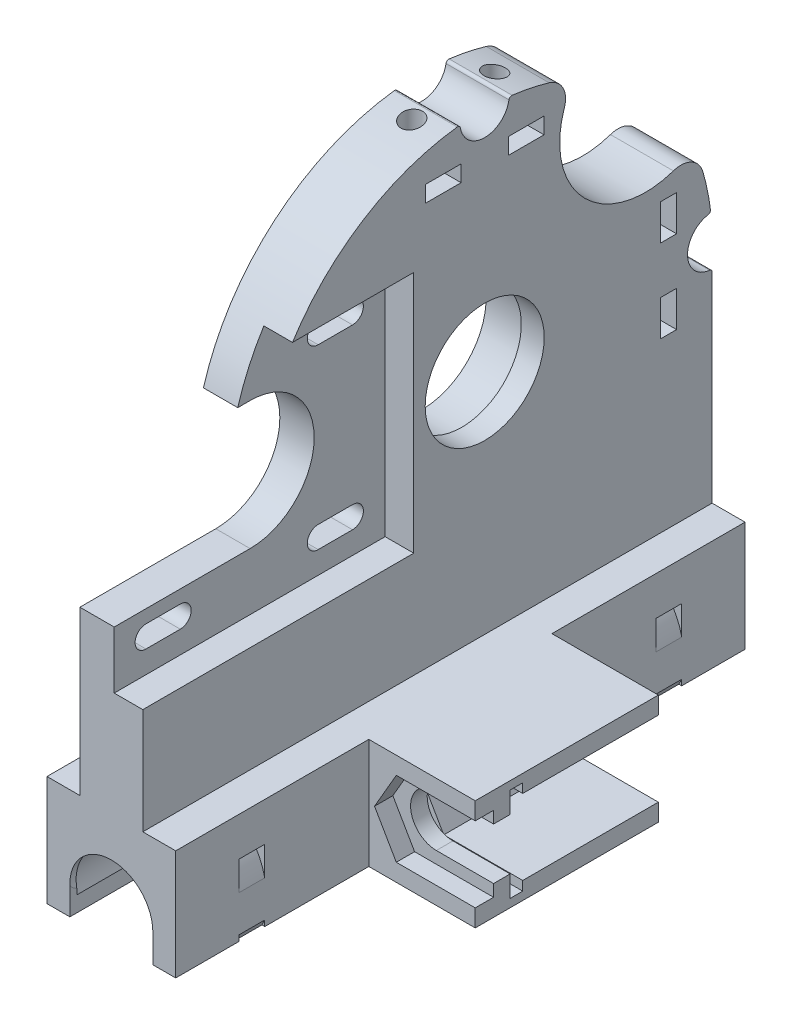
from build123d import *

# Parameters (mm, degrees)
CROQUIS1_W                          = 2.85
CROQUIS1_H                          = 6.25
CROQUIS1_R                          = 10.4
CROQUIS1_W_2                        = 6.25
CROQUIS1_H_2                        = 2.85
SALIENTE_EXTRUIR1_DEPTH             = 11
SALIENTE_EXTRUIR2_DEPTH             = 6
CROQUIS2_R                          = 11.25
CORTAR_EXTRUIR1_DEPTH               = 7
CROQUIS3_R                          = 1.875
CORTAR_EXTRUIR2_DEPTH               = 20
CROQUIS4_R                          = 1.875
CORTAR_EXTRUIR3_DEPTH               = 20
SALIENTE_EXTRUIR4_DEPTH             = 2.85
SALIENTE_EXTRUIR5_DEPTH             = 2.85
SALIENTE_EXTRUIR6_REACH             = 51.75
SALIENTE_EXTRUIR6_DIRECTION_2_REACH = 51.75
CORTAR_EXTRUIR4_DEPTH               = 2.25
CROQUIS10_W                         = 32
CROQUIS10_H                         = 19.25
SALIENTE_EXTRUIR7_DEPTH             = 18.6
CORTAR_EXTRUIR5_DEPTH               = 37.95
CORTAR_EXTRUIR5_DEPTH_BACK          = 63.55
SALIENTE_EXTRUIR8_DEPTH             = 2.9
CORTAR_EXTRUIR7_DEPTH               = 2.2
CROQUIS14_R                         = 15
CORTAR_EXTRUIR8_DEPTH               = 17.75
REDONDEO1_R                         = 4


with BuildPart() as part:
    # Croquis1 → Saliente-Extruir1 (new body)
    with BuildSketch(Plane(origin=(0, 0, 0), x_dir=(0, 0, -1), z_dir=(1, 0, 0))):
        with BuildLine():
            Line((-2.4, 18.5), (-49.75, 18.5))
            Line((-49.75, 18.5), (-49.75, 0))
            Line((-49.75, 0), (49.75, 0))
            Line((49.75, 0), (49.75, 34.976112695))
            ThreePointArc((49.75, 34.976112695), (49.621511552, 35.310745579), (49.302083333, 35.473392623))
            ThreePointArc((49.302083333, 35.473392623), (45.451952669, 39.620427093), (49.045277778, 43.99185886))
            ThreePointArc((49.045277778, 43.99185886), (49.363598896, 44.185452673), (49.459681529, 44.545417986))
            ThreePointArc((49.459681529, 44.545417986), (38.107494552, 67.857494552), (14.795417986, 79.209681529))
            ThreePointArc((14.795417986, 79.209681529), (14.435452673, 79.113598896), (14.24185886, 78.795277778))
            ThreePointArc((14.24185886, 78.795277778), (10, 75.2), (5.75814114, 78.795277778))
            ThreePointArc((5.75814114, 78.795277778), (5.564547327, 79.113598896), (5.204582014, 79.209681529))
            ThreePointArc((5.204582014, 79.209681529), (-11.244263728, 73.346781969), (-23.593154064, 61))
            Line((-23.593154064, 61), (-2.4, 61))
            Line((-2.4, 61), (-2.4, 18.5))
        make_face()
        with Locations((42.115, 32.5)):
            Rectangle(CROQUIS1_W, CROQUIS1_H, mode=Mode.SUBTRACT)
        with Locations((10, 39.75)):
            Circle(CROQUIS1_R, mode=Mode.SUBTRACT)
        with Locations((42.115, 47)):
            Rectangle(CROQUIS1_W, CROQUIS1_H, mode=Mode.SUBTRACT)
        with Locations((2.75, 71.865)):
            Rectangle(CROQUIS1_W_2, CROQUIS1_H_2, mode=Mode.SUBTRACT)
        with Locations((17.25, 71.865)):
            Rectangle(CROQUIS1_W_2, CROQUIS1_H_2, mode=Mode.SUBTRACT)
    extrude(amount=SALIENTE_EXTRUIR1_DEPTH)

    # Croquis1_3 → Saliente-Extruir2 (add)
    with BuildSketch(Plane(origin=(0, 0, 0), x_dir=(0, 0, -1), z_dir=(1, 0, 0))):
        with BuildLine():
            ThreePointArc((-26, 50.900169894), (-14.799915053, 39.700084947), (-26, 28.5))
            Line((-26, 28.5), (-49.75, 28.5))
            Line((-49.75, 28.5), (-49.75, 18.5))
            Line((-49.75, 18.5), (-2.4, 18.5))
            Line((-2.4, 18.5), (-2.4, 61))
            Line((-2.4, 61), (-23.593154064, 61))
            ThreePointArc((-23.593154064, 61), (-26.227326218, 56.109808528), (-28.154111329, 50.900169894))
            Line((-28.154111329, 50.900169894), (-26, 50.900169894))
        make_face()
        with BuildLine():
            ThreePointArc((-44.2, 22.4), (-46.1, 24.3), (-44.2, 26.2))
            Line((-44.2, 26.2), (-38.2, 26.2))
            ThreePointArc((-38.2, 26.2), (-36.3, 24.3), (-38.2, 22.4))
            Line((-38.2, 22.4), (-44.2, 22.4))
        make_face(mode=Mode.SUBTRACT)
        with BuildLine():
            ThreePointArc((-14.1, 22.4), (-16, 24.3), (-14.1, 26.2))
            Line((-14.1, 26.2), (-8.1, 26.2))
            ThreePointArc((-8.1, 26.2), (-6.2, 24.3), (-8.1, 22.4))
            Line((-8.1, 22.4), (-14.1, 22.4))
        make_face(mode=Mode.SUBTRACT)
        with BuildLine():
            ThreePointArc((-14.1, 53.4), (-16, 55.3), (-14.1, 57.2))
            Line((-14.1, 57.2), (-8.1, 57.2))
            ThreePointArc((-8.1, 57.2), (-6.2, 55.3), (-8.1, 53.4))
            Line((-8.1, 53.4), (-14.1, 53.4))
        make_face(mode=Mode.SUBTRACT)
    extrude(amount=SALIENTE_EXTRUIR2_DEPTH)

    # Croquis2 → Cortar-Extruir1 (cut)
    with BuildSketch(Plane.ZY):
        with Locations((-10, 39.75)):
            Circle(CROQUIS2_R)
    extrude(amount=-CORTAR_EXTRUIR1_DEPTH, mode=Mode.SUBTRACT)

    # Croquis3 → Cortar-Extruir2 (cut)
    with BuildSketch(Plane(origin=(0, 0, -49.75), x_dir=(-1, 0, 0), z_dir=(0, 0, -1))):
        with Locations((-5.5, 46.982625741)):
            Circle(CROQUIS3_R)
        with Locations((-5.5, 32.482625741)):
            Circle(CROQUIS3_R)
    extrude(amount=-CORTAR_EXTRUIR2_DEPTH, mode=Mode.SUBTRACT)

    # Croquis4 → Cortar-Extruir3 (cut)
    with BuildSketch(Plane(origin=(0, 79.209681529, 0), x_dir=(1, 0, 0), z_dir=(0, 1, 0))):
        with Locations((5.5, 2.75)):
            Circle(CROQUIS4_R)
        with Locations((5.5, 17.25)):
            Circle(CROQUIS4_R)
    extrude(amount=-CORTAR_EXTRUIR3_DEPTH, mode=Mode.SUBTRACT)

    # Croquis5 → Saliente-Extruir4 (add)
    with BuildSketch(Plane(origin=(0, 0, -40.69), x_dir=(-1, 0, 0), z_dir=(0, 0, -1))):
        Polygon((-1.9, 46.982625741), (-3.694188558, 43.875), (0, 43.875), (0, 50.125), (-3.714250624, 50.125), align=None)
        Polygon((-1.9, 32.482625741), (-3.694188558, 29.375), (0, 29.375), (0, 35.625), (-3.714250624, 35.625), align=None)
    extrude(amount=SALIENTE_EXTRUIR4_DEPTH)

    # Croquis6 → Saliente-Extruir5 (add)
    with BuildSketch(Plane(origin=(0, 70.44, 0), x_dir=(1, 0, 0), z_dir=(0, 1, 0))):
        Polygon((3.704219591, -0.375), (1.9, 2.75), (3.704219591, 5.875), (0, 5.875), (0, -0.375), align=None)
        Polygon((1.9, 17.25), (3.704219591, 20.375), (0, 20.375), (0, 14.125), (3.704219591, 14.125), align=None)
    extrude(amount=SALIENTE_EXTRUIR5_DEPTH)

    # Saliente-Extruir6: up to this face of the body (flat: up to its plane)
    saliente_extruir6_end = Plane(part.part.faces().sort_by_distance((5.5, 17.044884726, -49.75))[0])
    # Croquis7 → Saliente-Extruir6 (add, up to the picked face)
    with BuildSketch(Plane.XY, mode=Mode.PRIVATE) as saliente_extruir6_sk1:
        with BuildLine():
            Line((-1.75, -19.25), (-5.75, -19.25))
            Line((-5.75, -19.25), (-5.75, 0))
            Line((-5.75, 0), (16.75, 0))
            Line((16.75, 0), (16.75, -19.25))
            Line((16.75, -19.25), (12.75, -19.25))
            Line((12.75, -19.25), (12.75, -14.25))
            ThreePointArc((12.75, -14.25), (5.5, -7), (-1.75, -14.25))
            Line((-1.75, -14.25), (-1.75, -19.25))
        make_face()
    saliente_extruir6_tool1 = split(extrude(saliente_extruir6_sk1.sketch, amount=-SALIENTE_EXTRUIR6_REACH, mode=Mode.PRIVATE), bisect_by=saliente_extruir6_end, keep=Keep.BOTH, mode=Mode.PRIVATE)
    add(saliente_extruir6_tool1.solids().sort_by_distance((-2.04611, -16.75, 0))[0])

    # Saliente-Extruir6 direction 2: up to this face of the body (flat: up to its plane)
    saliente_extruir6_direction_2_end = Plane(part.part.faces().sort_by_distance((4.930740038, 12.494781784, 49.75))[0])
    # Croquis7 → Saliente-Extruir6 direction 2 (add, up to the picked face)
    with BuildSketch(Plane.XY, mode=Mode.PRIVATE) as saliente_extruir6_direction_2_sk1:
        with BuildLine():
            Line((-1.75, -19.25), (-5.75, -19.25))
            Line((-5.75, -19.25), (-5.75, 0))
            Line((-5.75, 0), (16.75, 0))
            Line((16.75, 0), (16.75, -19.25))
            Line((16.75, -19.25), (12.75, -19.25))
            Line((12.75, -19.25), (12.75, -14.25))
            ThreePointArc((12.75, -14.25), (5.5, -7), (-1.75, -14.25))
            Line((-1.75, -14.25), (-1.75, -19.25))
        make_face()
    saliente_extruir6_direction_2_tool1 = split(extrude(saliente_extruir6_direction_2_sk1.sketch, amount=SALIENTE_EXTRUIR6_DIRECTION_2_REACH, mode=Mode.PRIVATE), bisect_by=saliente_extruir6_direction_2_end, keep=Keep.BOTH, mode=Mode.PRIVATE)
    add(saliente_extruir6_direction_2_tool1.solids().sort_by_distance((-2.04611, -16.75, 0))[0])

    # Croquis8 → Cortar-Revolución1 (revolve, cut)
    with BuildSketch(Plane(origin=(0, -14.25, 0), x_dir=(-1, 0, 0), z_dir=(0, -1, 0))):
        Polygon((-12.75, 23.134002855), (-5.5, 23.134002855), (-5.5, 49.75), (-12.75, 49.75), (-12.863925069, 48.542001427), (-13.1, 48.542001427), (-13.1, 24.342001427), (-12.863925069, 24.342001427), align=None)
    cortar_revoluci_n1 = revolve(axis=Axis((5.5, -14.25, -23.134002855), (0, 0, -1)), mode=Mode.SUBTRACT)

    # Simetría1: Cortar-Revolución1 across plane
    add(cortar_revoluci_n1.mirror(Plane.XY), mode=Mode.SUBTRACT)

    # Croquis9 → Cortar-Extruir4 (cut, symmetric)
    with BuildSketch(Plane(origin=(0, 0, -36.442001427), x_dir=(-1, 0, 0), z_dir=(0, 0, -1))):
        with BuildLine():
            Line((-16.75, -6.787594222), (-16.75, -11.865151996))
            ThreePointArc((-16.75, -11.865151996), (-5.5, -2.75), (5.75, -11.865151996))
            Line((5.75, -11.865151996), (5.75, -6.787594222))
            ThreePointArc((5.75, -6.787594222), (-5.5, -0.75), (-16.75, -6.787594222))
        make_face()
        Polygon((5.75, -18.25), (5.25, -19.25), (5.75, -19.25), align=None)
        Polygon((-16.75, -19.25), (-16.25, -19.25), (-16.75, -18.25), align=None)
    cortar_extruir4 = extrude(amount=CORTAR_EXTRUIR4_DEPTH, both=True, mode=Mode.SUBTRACT)

    # Simetría2: Cortar-Extruir4 across plane
    add(cortar_extruir4.mirror(Plane.XY), mode=Mode.SUBTRACT)

    # Croquis10 → Saliente-Extruir7 (add)
    with BuildSketch(Plane(origin=(16.75, 0, 0), x_dir=(0, 0, -1), z_dir=(1, 0, 0))):
        with Locations((0, -9.625)):
            Rectangle(CROQUIS10_W, CROQUIS10_H)
    extrude(amount=SALIENTE_EXTRUIR7_DEPTH)

    # Croquis11 → Cortar-Extruir5 (cut, two sides)
    with BuildSketch(Plane.XY.offset(12.8)) as cortar_extruir5_sk:
        with BuildLine():
            Line((35.35, -14.125), (35.35, -5.125))
            Line((35.35, -5.125), (25.35, -5.125))
            ThreePointArc((25.35, -5.125), (20.85, -9.625), (25.35, -14.125))
            Line((25.35, -14.125), (35.35, -14.125))
        make_face()
        with BuildLine():
            Line((35.35, -14.125), (35.35, -5.125))
            Line((35.35, -5.125), (25.35, -5.125))
            ThreePointArc((25.35, -5.125), (20.85, -9.625), (25.35, -14.125))
            Line((25.35, -14.125), (35.35, -14.125))
        make_face()
        with BuildLine():
            Line((35.35, -14.125), (35.35, -5.125))
            Line((35.35, -5.125), (25.35, -5.125))
            ThreePointArc((25.35, -5.125), (20.85, -9.625), (25.35, -14.125))
            Line((25.35, -14.125), (35.35, -14.125))
        make_face()
        with BuildLine():
            Line((35.35, -3.043), (21.55047791, -3.043))
            Line((21.55047791, -3.043), (17.750358438, -9.625))
            Line((17.750358438, -9.625), (21.55047791, -16.207))
            Line((21.55047791, -16.207), (35.35, -16.207))
            Line((35.35, -16.207), (35.35, -14.125))
            Line((35.35, -14.125), (25.35, -14.125))
            ThreePointArc((25.35, -14.125), (20.85, -9.625), (25.35, -5.125))
            Line((25.35, -5.125), (35.35, -5.125))
            Line((35.35, -5.125), (35.35, -3.043))
        make_face()
    extrude(amount=CORTAR_EXTRUIR5_DEPTH, mode=Mode.SUBTRACT)
    extrude(cortar_extruir5_sk.sketch, amount=-CORTAR_EXTRUIR5_DEPTH_BACK, mode=Mode.SUBTRACT)

    # Croquis11_3 → Saliente-Extruir8 (add)
    with BuildSketch(Plane.XY.offset(12.8)):
        with BuildLine():
            Line((35.35, -3.043), (21.55047791, -3.043))
            Line((21.55047791, -3.043), (17.750358438, -9.625))
            Line((17.750358438, -9.625), (21.55047791, -16.207))
            Line((21.55047791, -16.207), (35.35, -16.207))
            Line((35.35, -16.207), (35.35, -14.125))
            Line((35.35, -14.125), (25.35, -14.125))
            ThreePointArc((25.35, -14.125), (20.85, -9.625), (25.35, -5.125))
            Line((25.35, -5.125), (35.35, -5.125))
            Line((35.35, -5.125), (35.35, -3.043))
        make_face()
    extrude(amount=-SALIENTE_EXTRUIR8_DEPTH)

    # Croquis13 → Cortar-Extruir7 (cut)
    with BuildSketch(Plane(origin=(0, 0, 9.9), x_dir=(-1, 0, 0), z_dir=(0, 0, -1))):
        with BuildLine():
            Line((-35.35, -16.207), (-35.35, -17.825))
            Line((-35.35, -17.825), (-25.35, -17.825))
            ThreePointArc((-25.35, -17.825), (-17.15, -9.625), (-25.35, -1.425))
            Line((-25.35, -1.425), (-35.35, -1.425))
            Line((-35.35, -1.425), (-35.35, -3.043))
            Line((-35.35, -3.043), (-21.55047791, -3.043))
            Line((-21.55047791, -3.043), (-17.750358438, -9.625))
            Line((-17.750358438, -9.625), (-21.55047791, -16.207))
            Line((-21.55047791, -16.207), (-35.35, -16.207))
        make_face()
        with BuildLine():
            Line((-35.35, -14.125), (-35.35, -16.207))
            Line((-35.35, -16.207), (-21.55047791, -16.207))
            Line((-21.55047791, -16.207), (-17.750358438, -9.625))
            Line((-17.750358438, -9.625), (-21.55047791, -3.043))
            Line((-21.55047791, -3.043), (-35.35, -3.043))
            Line((-35.35, -3.043), (-35.35, -5.125))
            Line((-35.35, -5.125), (-25.35, -5.125))
            ThreePointArc((-25.35, -5.125), (-20.85, -9.625), (-25.35, -14.125))
            Line((-25.35, -14.125), (-35.35, -14.125))
        make_face()
    extrude(amount=CORTAR_EXTRUIR7_DEPTH, mode=Mode.SUBTRACT)

    # Croquis14 → Cortar-Extruir8 (cut, through all)
    with BuildSketch(Plane(origin=(11, 0, 0), x_dir=(0, 0, -1), z_dir=(1, 0, 0))):
        with Locations((38.107494552, 67.857494552)):
            Circle(CROQUIS14_R)
    extrude(amount=-CORTAR_EXTRUIR8_DEPTH, mode=Mode.SUBTRACT)

    # Redondeo1
    redondeo1_edges = [part.edges().sort_by_distance(p)[0] for p in [
        (5.5, 55.440154858, -46.522343032),
        (5.5, 76.272343032, -25.690154858),
    ]]
    fillet(redondeo1_edges, radius=REDONDEO1_R)


solid = part.part
